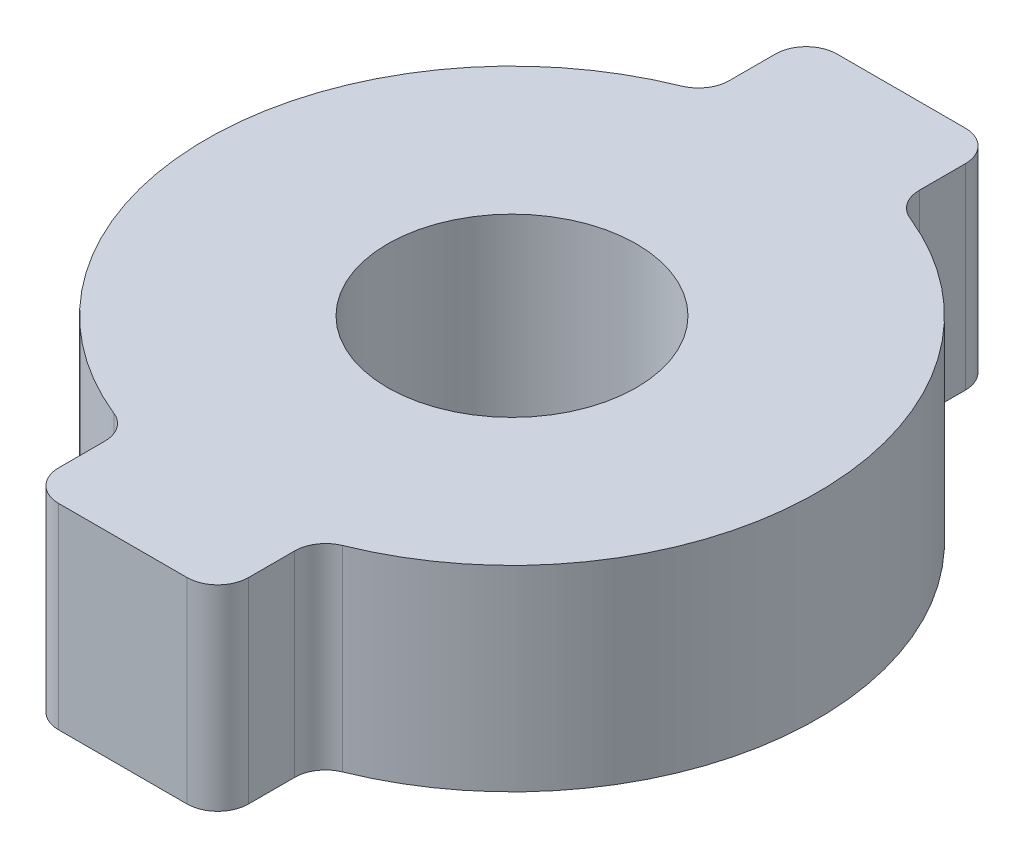
from build123d import *

# Parameters (mm, degrees)
SKETCH1_R           = 9.9
SKETCH1_R_2         = 4.03
BOSS_EXTRUDE1_DEPTH = 6.35
SKETCH2_W           = 6.15
SKETCH2_H           = 3.189666584
BOSS_EXTRUDE2_DEPTH = 6.35
FILLET2_R           = 1


with BuildPart() as part:
    # Sketch1 → Boss-Extrude1 (new body)
    with BuildSketch(Plane(origin=(0, 0, 0), x_dir=(1, 0, 0), z_dir=(0, 1, 0))):
        Circle(SKETCH1_R)
        Circle(SKETCH1_R_2, mode=Mode.SUBTRACT)
    extrude(amount=BOSS_EXTRUDE1_DEPTH)

    # Sketch2 → Boss-Extrude2 (add, through all)
    with BuildSketch(Plane.XZ):
        with Locations((0, 11.005166708)):
            Rectangle(SKETCH2_W, SKETCH2_H)
        with Locations((0, -11.005166708)):
            Rectangle(SKETCH2_W, SKETCH2_H)
    extrude(amount=-BOSS_EXTRUDE2_DEPTH)

    # Fillet2
    fillet2_edges = [part.edges().sort_by_distance(p)[0] for p in [
        (-3.075, 3.175, 9.410333416),
        (-3.075, 3.175, 12.6),
        (3.075, 3.175, 12.6),
        (3.075, 3.175, 9.410333416),
        (-3.075, 3.175, -12.6),
        (-3.075, 3.175, -9.410333416),
        (3.075, 3.175, -9.410333416),
        (3.075, 3.175, -12.6),
    ]]
    fillet(fillet2_edges, radius=FILLET2_R)


solid = part.part
